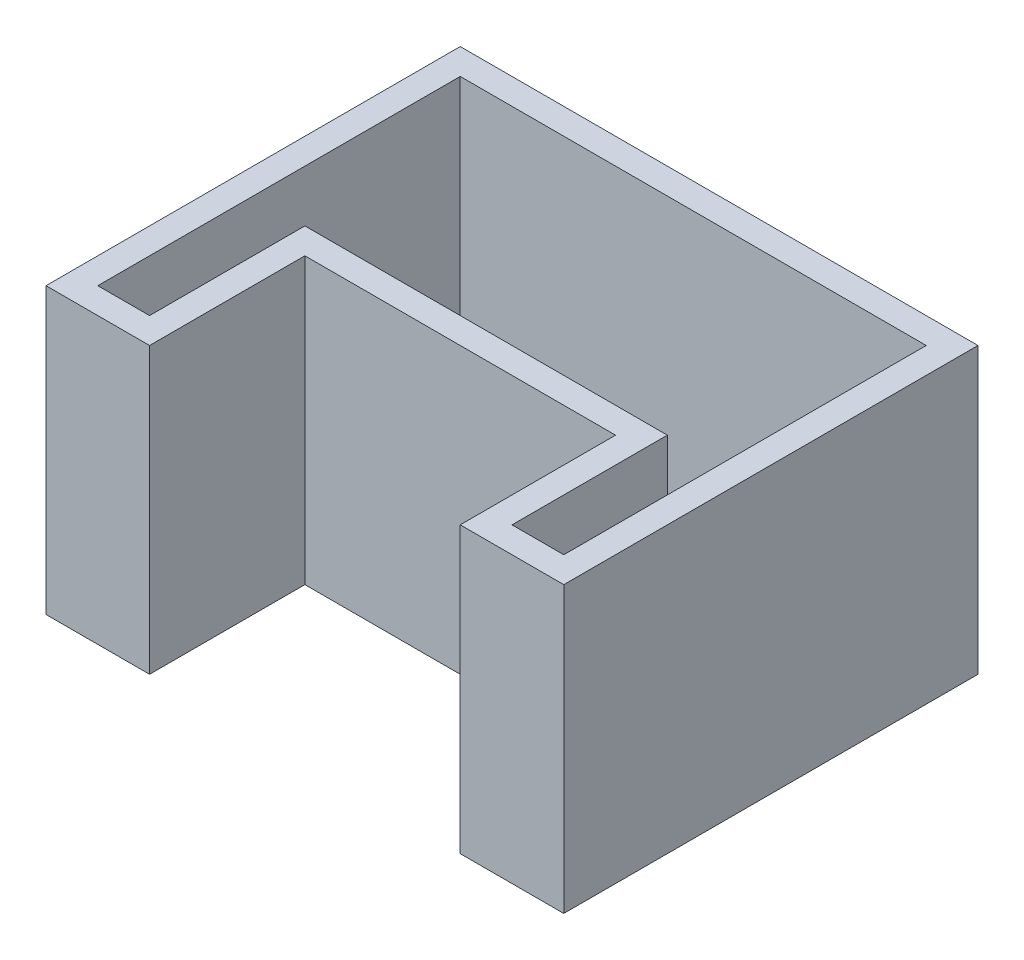
from build123d import *

# Parameters (mm, degrees)
BOSS_EXTRUDE1_DEPTH = 10
BOSS_EXTRUDE2_DEPTH = 100
SKETCH4_R           = 5
CUT_EXTRUDE1_DEPTH  = 10


with BuildPart() as part:
    # Sketch2 → Boss-Extrude1 (new body)
    with BuildSketch(Plane(origin=(0, 0, 0), x_dir=(1, 0, 0), z_dir=(0, 1, 0))):
        Polygon((-60, -80), (-60, -20), (60, -20), (60, -80), (100, -80), (100, 80), (-100, 80), (-100, -80), align=None)
    extrude(amount=BOSS_EXTRUDE1_DEPTH)

    # Sketch3 → Boss-Extrude2 (add)
    with BuildSketch(Plane(origin=(0, 10, 0), x_dir=(1, 0, 0), z_dir=(0, 1, 0))):
        Polygon((-60, -80), (-60, -20), (60, -20), (60, -80), (100, -80), (100, 80), (-100, 80), (-100, -80), align=None)
        Polygon((90, 70), (-90, 70), (-90, -70), (-70, -70), (-70, -10), (70, -10), (70, -70), (90, -70), align=None, mode=Mode.SUBTRACT)
    extrude(amount=BOSS_EXTRUDE2_DEPTH)

    # Sketch4 → Cut-Extrude1 (cut)
    with BuildSketch(Plane(origin=(0, 10, 0), x_dir=(1, 0, 0), z_dir=(0, 1, 0))):
        with Locations((0, 23.078006165)):
            Circle(SKETCH4_R)
    extrude(amount=-CUT_EXTRUDE1_DEPTH, mode=Mode.SUBTRACT)


solid = part.part
